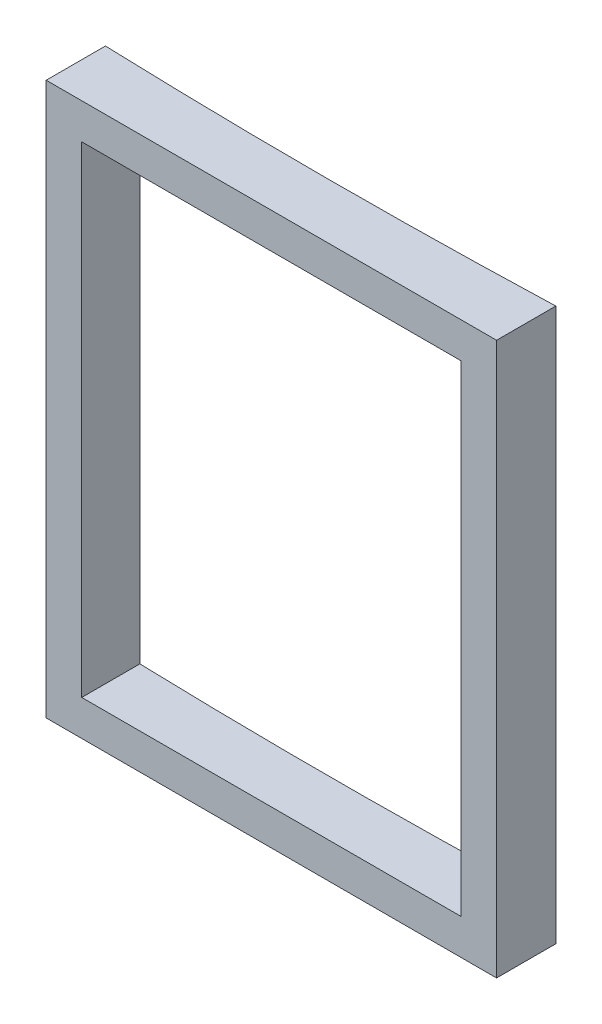
from build123d import *

# Parameters (mm, degrees)
BOSS_EXTRUDE1_DEPTH = 2330
SKETCH3_W           = 1600
SKETCH3_H           = 2030
CUT_EXTRUDE1_DEPTH  = 3000


with BuildPart() as part:
    # Sketch2 → Boss-Extrude1 (new body)
    with BuildSketch(Plane(origin=(0, 0, 0), x_dir=(1, 0, 0), z_dir=(0, 1, 0))):
        with BuildLine():
            Line((-6692.186143144, -5017.367964626), (-6692.186143144, -5267.367964626))
            Line((-6692.186143144, -5267.367964626), (-8592.186143144, -5267.367964626))
            Line((-8592.186143144, -5267.367964626), (-8592.186143144, -5017.367964626))
            ThreePointArc((-8592.186143144, -5017.367964626), (-7642.186143144, -5033.781954063), (-6692.186143144, -5017.367964626))
        make_face()
    extrude(amount=BOSS_EXTRUDE1_DEPTH)

    # Sketch3 → Cut-Extrude1 (cut)
    with BuildSketch(Plane.XY.offset(5267.367964626)):
        with Locations((-7642.186143144, 1165)):
            Rectangle(SKETCH3_W, SKETCH3_H)
    extrude(amount=-CUT_EXTRUDE1_DEPTH, mode=Mode.SUBTRACT)


solid = part.part
